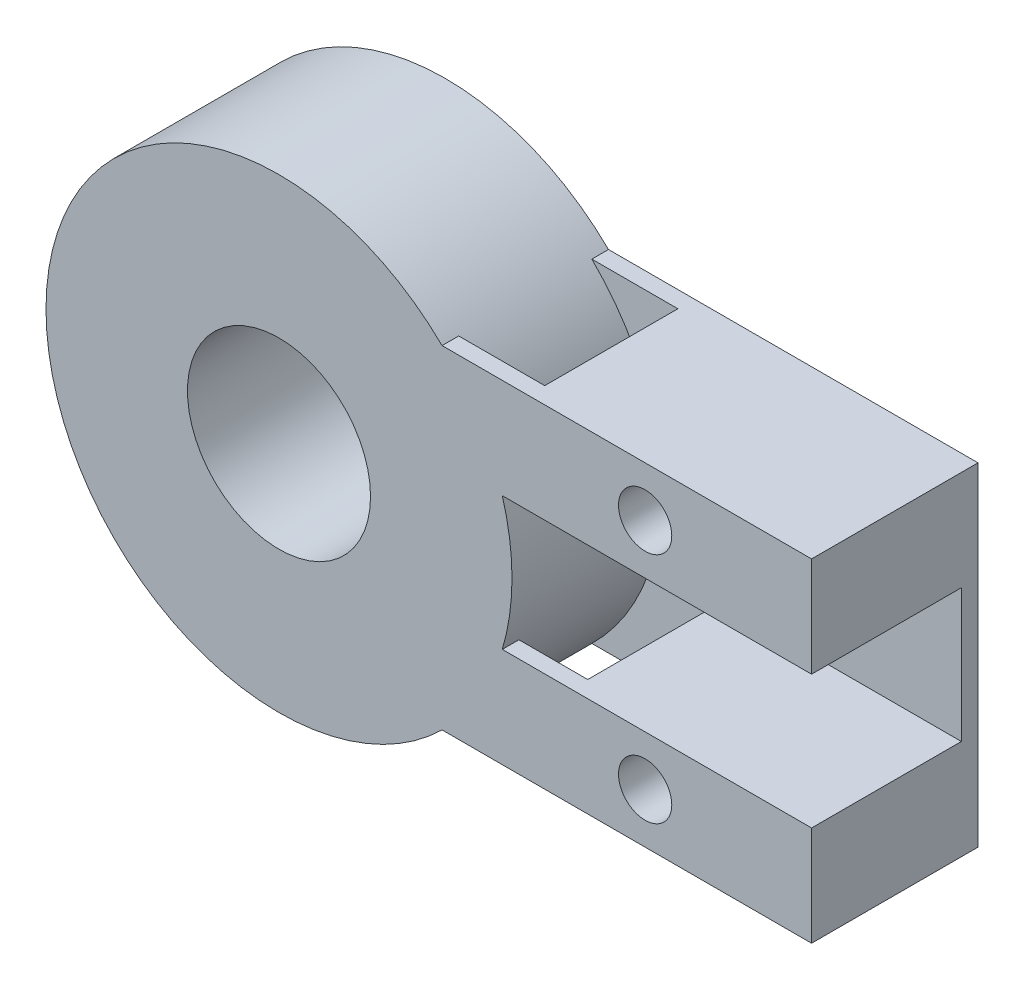
from build123d import *
from build123d.topology import SkipClean

# Parameters (mm, degrees)
BOSS_EXTRUDE1_DEPTH = 5
SKETCH3_R           = 2.75
JOINT_HOLE_DEPTH    = 32.253054869
CUT_EXTRUDE2_START  = 0.5
CUT_EXTRUDE2_DEPTH  = 5.5
SKETCH7_R           = 0.8
SCREW_HOLES_DEPTH   = 32.253054869
BOSS_EXTRUDE2_START = 5
SKETCH10_W          = 3.875984902
SKETCH10_H          = 3
BOSS_EXTRUDE2_DEPTH = 0.5


with BuildPart() as part:
    # Sketch1 → Boss-Extrude1 (new body)
    with BuildSketch(Plane.XY):
        with BuildLine():
            Line((22.456085085, 19.15366827), (11.355064571, 19.15366827))
            ThreePointArc((11.355064571, 19.15366827), (-0.543914915, 14.15366827), (11.355064571, 9.15366827))
            Line((11.355064571, 9.15366827), (22.456085085, 9.15366827))
            Line((22.456085085, 9.15366827), (22.456085085, 19.15366827))
        make_face()
    extrude(amount=BOSS_EXTRUDE1_DEPTH)

    # Sketch3 → Joint Hole (cut, through all)
    with BuildSketch(Plane.XY):
        with Locations((6.456085085, 14.15366827)):
            Circle(SKETCH3_R)
    extrude(amount=JOINT_HOLE_DEPTH, mode=Mode.SUBTRACT)

    # Sketch8 → Cut-Extrude2 (cut)
    with SkipClean():  # the faces are left unmerged after this step: merging them gives an invalid solid
        with BuildSketch(Plane.XY.offset(CUT_EXTRUDE2_START)):
            with BuildLine():
                Line((22.456085085, 16.15366827), (15.231049473, 16.15366827))
                ThreePointArc((15.231049473, 16.15366827), (14.722457344, 17.712753782), (13.939399859, 19.15366827))
                Line((13.939399859, 19.15366827), (11.355064571, 19.15366827))
                ThreePointArc((11.355064571, 19.15366827), (13.456085085, 14.15366827), (11.355064571, 9.15366827))
                Line((11.355064571, 9.15366827), (13.939399859, 9.15366827))
                ThreePointArc((13.939399859, 9.15366827), (14.722457344, 10.594582758), (15.231049473, 12.15366827))
                Line((15.231049473, 12.15366827), (22.456085085, 12.15366827))
                Line((22.456085085, 12.15366827), (22.456085085, 16.15366827))
            make_face()
        extrude(amount=CUT_EXTRUDE2_DEPTH, mode=Mode.SUBTRACT)

    # Sketch7 → Screw Holes (cut, through all)
    with SkipClean():  # the faces are left unmerged after this step: merging them gives an invalid solid
        with BuildSketch(Plane.XY):
            with Locations((17.456085085, 17.65366827)):
                Circle(SKETCH7_R)
            with Locations((17.456085085, 10.65366827)):
                Circle(SKETCH7_R)
        extrude(amount=SCREW_HOLES_DEPTH, mode=Mode.SUBTRACT)

    # Sketch10 → Boss-Extrude2 (add)
    with SkipClean():  # the faces are left unmerged after this step: merging them gives an invalid solid
        with BuildSketch(Plane.XY.offset(BOSS_EXTRUDE2_START)):
            with Locations((13.293057022, 17.65366827)):
                Rectangle(SKETCH10_W, SKETCH10_H)
            with Locations((13.293057022, 10.65366827)):
                Rectangle(SKETCH10_W, SKETCH10_H)
        extrude(amount=-BOSS_EXTRUDE2_DEPTH)


solid = part.part
